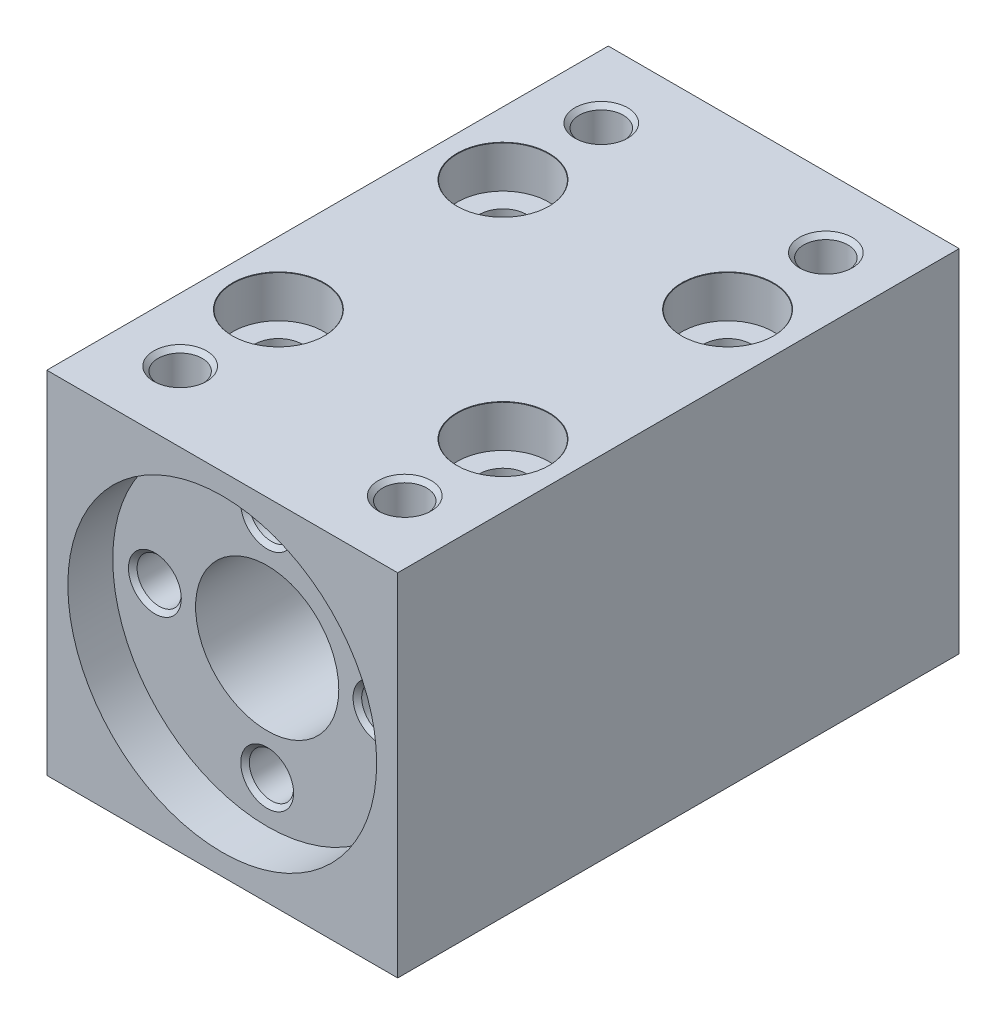
from build123d import *

# Parameters (mm, degrees)
ESBO_O1_W                                         = 25
ESBO_O1_H                                         = 25
RESSALTO_EXTRUS_O1_DEPTH                          = 40
ESBO_O2_R                                         = 5.1
CORTE_EXTRUS_O1_DEPTH                             = 41
ESBO_O3_R                                         = 11
CORTE_EXTRUS_O2_DEPTH                             = 3.2
FURO_ROSCADO_PARA_CONDU_TE_DE_M3X0_52_D           = 3.15
FURO_ROSCADO_PARA_CONDU_TE_DE_M3X0_52_DEPTH       = 6
FURO_ROSCADO_PARA_CONDU_TE_DE_M3X0_52_CSINK_D     = 3.766
FURO_ROSCADO_PARA_CONDU_TE_DE_M3X0_52_CSINK_ANGLE = 90
FURO_ROSCADO_PARA_CONDU_TE_DE_M3X0_52_TIP         = 0.946355475
REBAIXO_PARA_SHCS_M31_AT_2_COUNT                  = 2
REBAIXO_PARA_SHCS_M31_AT_2_PITCH                  = 16
REBAIXO_PARA_SHCS_M31_AT_3_COUNT                  = 2
REBAIXO_PARA_SHCS_M31_AT_3_PITCH                  = 16
REBAIXO_PARA_SHCS_M31_AT_4_COUNT                  = 2
REBAIXO_PARA_SHCS_M31_AT_4_PITCH                  = 22.627416998
FURO_ROSCADO_PARA_CONDU_TE_DE_M3X0_53_D           = 3.15
FURO_ROSCADO_PARA_CONDU_TE_DE_M3X0_53_DEPTH       = 8
FURO_ROSCADO_PARA_CONDU_TE_DE_M3X0_53_CSINK_D     = 3.766
FURO_ROSCADO_PARA_CONDU_TE_DE_M3X0_53_CSINK_ANGLE = 90
FURO_ROSCADO_PARA_CONDU_TE_DE_M3X0_53_TIP         = 0.946355475


with BuildPart() as part:
    # Esboço1 → Ressalto-extrusão1 (new body)
    with BuildSketch(Plane.XY):
        Rectangle(ESBO_O1_W, ESBO_O1_H)
    extrude(amount=RESSALTO_EXTRUS_O1_DEPTH)

    # Esboço2 → Corte-extrusão1 (cut, through all)
    with BuildSketch(Plane.XY.offset(40)):
        Circle(ESBO_O2_R)
    extrude(amount=-CORTE_EXTRUS_O1_DEPTH, mode=Mode.SUBTRACT)

    # Esboço3 → Corte-extrusão2 (cut)
    with BuildSketch(Plane.XY.offset(40)):
        Circle(ESBO_O3_R)
    extrude(amount=-CORTE_EXTRUS_O2_DEPTH, mode=Mode.SUBTRACT)

    # Furo roscado para conduíte de M3x0.52
    with Locations(Plane.XY.offset(36.8)):
        with Locations((0, 8), (8, 0), (0, -8), (-8, 0)):
            CounterSinkHole(FURO_ROSCADO_PARA_CONDU_TE_DE_M3X0_52_D / 2, FURO_ROSCADO_PARA_CONDU_TE_DE_M3X0_52_CSINK_D / 2, depth=FURO_ROSCADO_PARA_CONDU_TE_DE_M3X0_52_DEPTH, counter_sink_angle=FURO_ROSCADO_PARA_CONDU_TE_DE_M3X0_52_CSINK_ANGLE)
            with Locations((0, 0, -(FURO_ROSCADO_PARA_CONDU_TE_DE_M3X0_52_DEPTH + FURO_ROSCADO_PARA_CONDU_TE_DE_M3X0_52_TIP / 2))):  # 118° drill point
                Cone(0, FURO_ROSCADO_PARA_CONDU_TE_DE_M3X0_52_D / 2, FURO_ROSCADO_PARA_CONDU_TE_DE_M3X0_52_TIP, mode=Mode.SUBTRACT)

    # Esboço13 → Rebaixo para SHCS M31 (revolve, cut)
    with BuildSketch(Plane(origin=(-8, 12.5, 12), x_dir=(0, 0, 1), z_dir=(1, 0, 0))):
        Polygon((0, 0), (0, 25), (1.7, 25), (1.7, 3), (3.25, 3), (3.25, 0.025), (3.275, 0), align=None)
    rebaixo_para_shcs_m31 = revolve(axis=Axis((-8, 18.85, 12), (0, -1, 0)), mode=Mode.SUBTRACT)

    # Rebaixo para SHCS M31 at 2: Rebaixo para SHCS M31 ×2
    with Locations(*[(i * REBAIXO_PARA_SHCS_M31_AT_2_PITCH, 0, 0) for i in range(1, REBAIXO_PARA_SHCS_M31_AT_2_COUNT)]):
        add(rebaixo_para_shcs_m31, mode=Mode.SUBTRACT)

    # Rebaixo para SHCS M31 at 3: Rebaixo para SHCS M31 ×2
    with Locations(*[(0, 0, i * REBAIXO_PARA_SHCS_M31_AT_3_PITCH) for i in range(1, REBAIXO_PARA_SHCS_M31_AT_3_COUNT)]):
        add(rebaixo_para_shcs_m31, mode=Mode.SUBTRACT)

    # Rebaixo para SHCS M31 at 4: Rebaixo para SHCS M31 ×2
    with Locations(*[Vector(0.707106781, 0, 0.707106781) * (i * REBAIXO_PARA_SHCS_M31_AT_4_PITCH) for i in range(1, REBAIXO_PARA_SHCS_M31_AT_4_COUNT)]):
        add(rebaixo_para_shcs_m31, mode=Mode.SUBTRACT)

    # Furo roscado para conduíte de M3x0.53
    with Locations(Plane(origin=(0, 12.5, 0), x_dir=(1, 0, 0), z_dir=(0, 1, 0))):
        with Locations((-8, -5), (8, -5), (-8, -35), (8, -35)):
            CounterSinkHole(FURO_ROSCADO_PARA_CONDU_TE_DE_M3X0_53_D / 2, FURO_ROSCADO_PARA_CONDU_TE_DE_M3X0_53_CSINK_D / 2, depth=FURO_ROSCADO_PARA_CONDU_TE_DE_M3X0_53_DEPTH, counter_sink_angle=FURO_ROSCADO_PARA_CONDU_TE_DE_M3X0_53_CSINK_ANGLE)
            with Locations((0, 0, -(FURO_ROSCADO_PARA_CONDU_TE_DE_M3X0_53_DEPTH + FURO_ROSCADO_PARA_CONDU_TE_DE_M3X0_53_TIP / 2))):  # 118° drill point
                Cone(0, FURO_ROSCADO_PARA_CONDU_TE_DE_M3X0_53_D / 2, FURO_ROSCADO_PARA_CONDU_TE_DE_M3X0_53_TIP, mode=Mode.SUBTRACT)


solid = part.part
